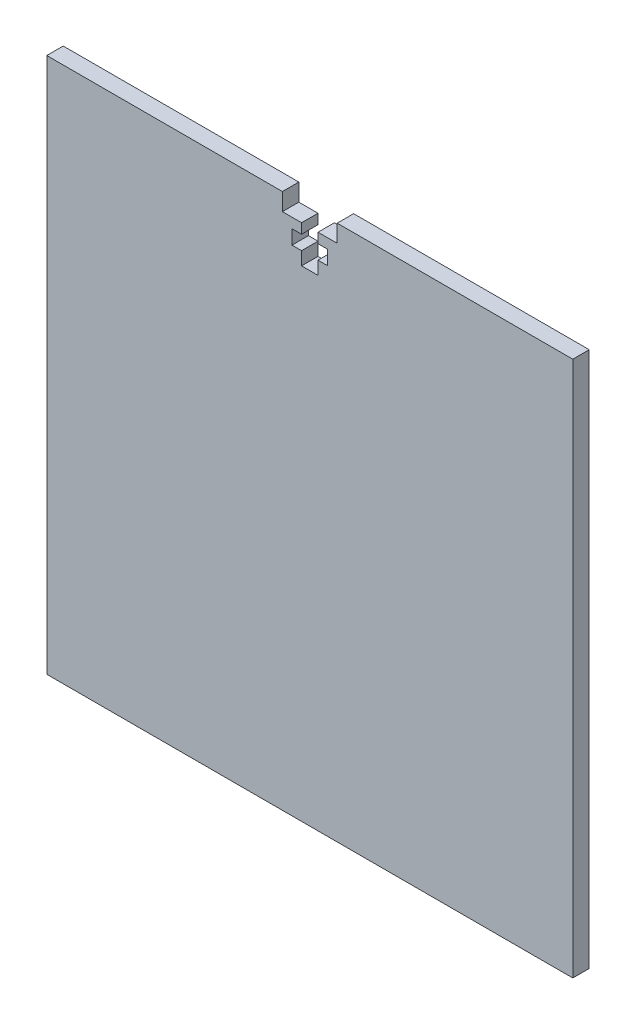
from build123d import *

# Parameters (mm, degrees)
SKETCH1_W           = 95.992410468
SKETCH1_H           = 97.798719266
BOSS_EXTRUDE1_DEPTH = 3
CUT_EXTRUDE1_DEPTH  = 4


with BuildPart() as part:
    # Sketch1 → Boss-Extrude1 (new body)
    with BuildSketch(Plane.XY):
        Rectangle(SKETCH1_W, SKETCH1_H)
    extrude(amount=BOSS_EXTRUDE1_DEPTH)

    # Sketch2 → Cut-Extrude1 (cut, through all)
    with BuildSketch(Plane.XY.offset(3)):
        Polygon((1.5, 45.719359633), (5, 45.719359633), (5, 48.899359633), (-5, 48.899359633), (-5, 45.719359633), (-1.5, 45.719359633), (-1.5, 43.899359633), (-3.25, 43.899359633), (-3.25, 41.299359633), (-1.5, 41.299359633), (-1.5, 38.899359633), (1.5, 38.899359633), (1.5, 41.299359633), (3.25, 41.299359633), (3.25, 43.899359633), (1.5, 43.899359633), align=None)
    extrude(amount=-CUT_EXTRUDE1_DEPTH, mode=Mode.SUBTRACT)


solid = part.part
